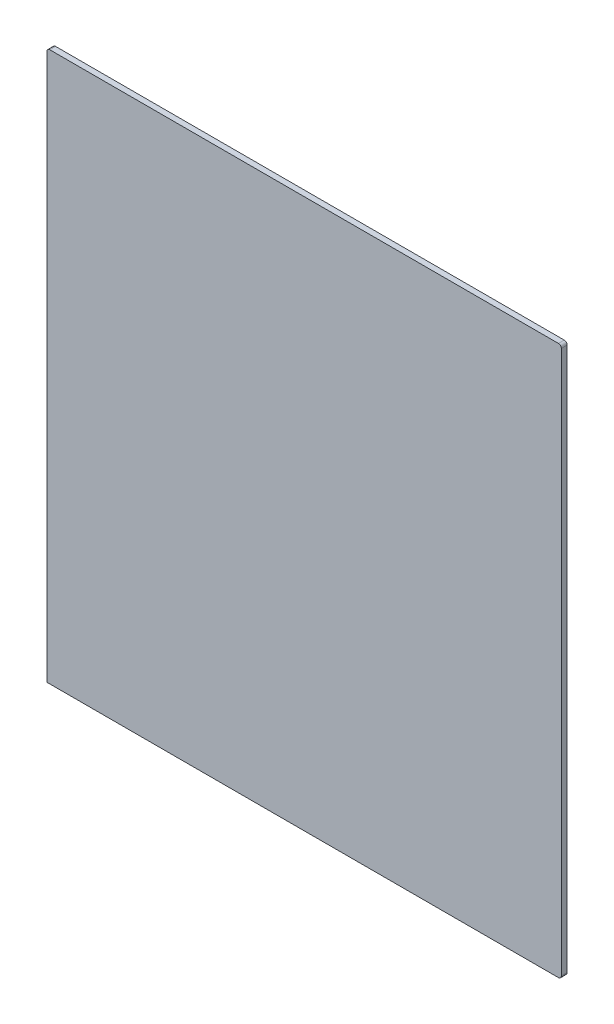
from build123d import *

# Parameters (mm, degrees)
EXTRUDE_1_DEPTH = 3


with BuildPart() as part:
    # 草图1 → 凸台-拉伸1 (new body)
    with BuildSketch(Plane.XY):
        with BuildLine():
            Line((-65.611088087, 40.275681374), (198.888911913, 40.275681374))
            ThreePointArc((198.888911913, 40.275681374), (199.949572085, 40.715021202), (200.388911913, 41.775681374))
            Line((200.388911913, 41.775681374), (200.388911913, 322.775681374))
            ThreePointArc((200.388911913, 322.775681374), (199.949572085, 323.836341546), (198.888911913, 324.275681374))
            Line((198.888911913, 324.275681374), (-64.111088087, 324.275681374))
            ThreePointArc((-64.111088087, 324.275681374), (-65.171748259, 323.836341546), (-65.611088087, 322.775681374))
            Line((-65.611088087, 322.775681374), (-65.611088087, 40.275681374))
        make_face()
    extrude(amount=EXTRUDE_1_DEPTH)


solid = part.part
